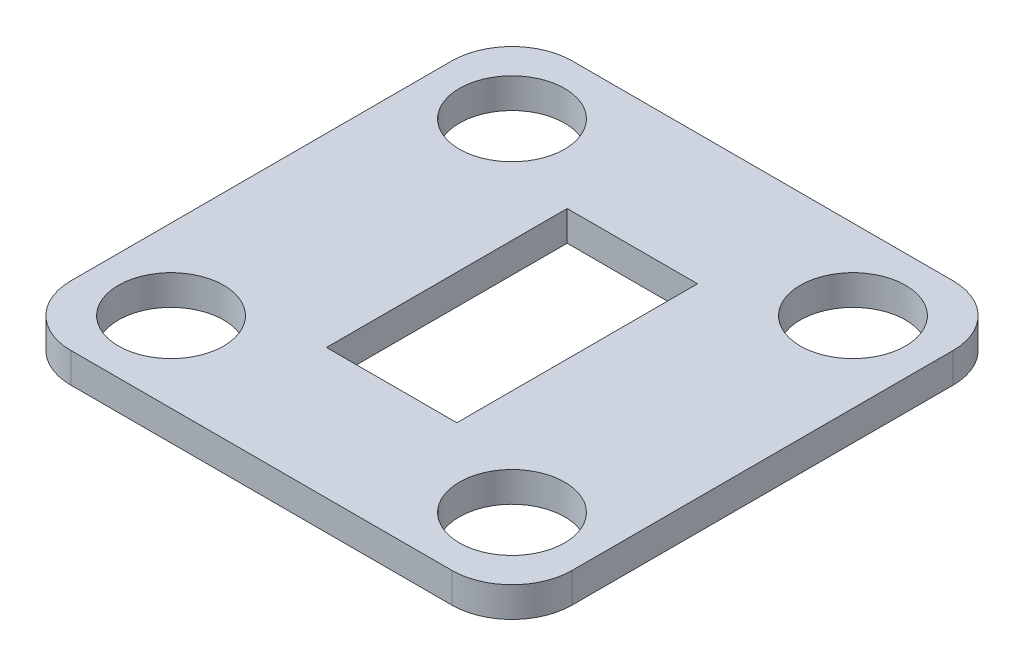
from build123d import *

# Parameters (mm, degrees)
SKETCH1_W           = 50
SKETCH1_H           = 50
BOSS_EXTRUDE1_DEPTH = 1.5
SKETCH2_R           = 5.25
CUT_EXTRUDE1_DEPTH  = 3
FILLET1_R           = 6
SKETCH3_W           = 13
SKETCH3_H           = 24
CUT_EXTRUDE2_DEPTH  = 3


with BuildPart() as part:
    # Sketch1 → Boss-Extrude1 (new body, symmetric)
    with BuildSketch(Plane(origin=(0, 0, 0), x_dir=(1, 0, 0), z_dir=(0, 1, 0))):
        Rectangle(SKETCH1_W, SKETCH1_H)
    extrude(amount=BOSS_EXTRUDE1_DEPTH, both=True)

    # Sketch2 → Cut-Extrude1 (cut)
    with BuildSketch(Plane(origin=(0, 1.5, 0), x_dir=(1, 0, 0), z_dir=(0, 1, 0))):
        with Locations((17, -17)):
            Circle(SKETCH2_R)
        with Locations((-17, -17)):
            Circle(SKETCH2_R)
        with Locations((-17, 17)):
            Circle(SKETCH2_R)
        with Locations((17, 17)):
            Circle(SKETCH2_R)
    extrude(amount=-CUT_EXTRUDE1_DEPTH, mode=Mode.SUBTRACT)

    # Fillet1
    fillet1_edges = [part.edges().sort_by_distance(p)[0] for p in [
        (25, 0, 25),
        (-25, 0, 25),
        (-25, 0, -25),
        (25, 0, -25),
    ]]
    fillet(fillet1_edges, radius=FILLET1_R)

    # Sketch3 → Cut-Extrude2 (cut)
    with BuildSketch(Plane.XZ.offset(1.5)):
        Rectangle(SKETCH3_W, SKETCH3_H)
    extrude(amount=-CUT_EXTRUDE2_DEPTH, mode=Mode.SUBTRACT)


solid = part.part
